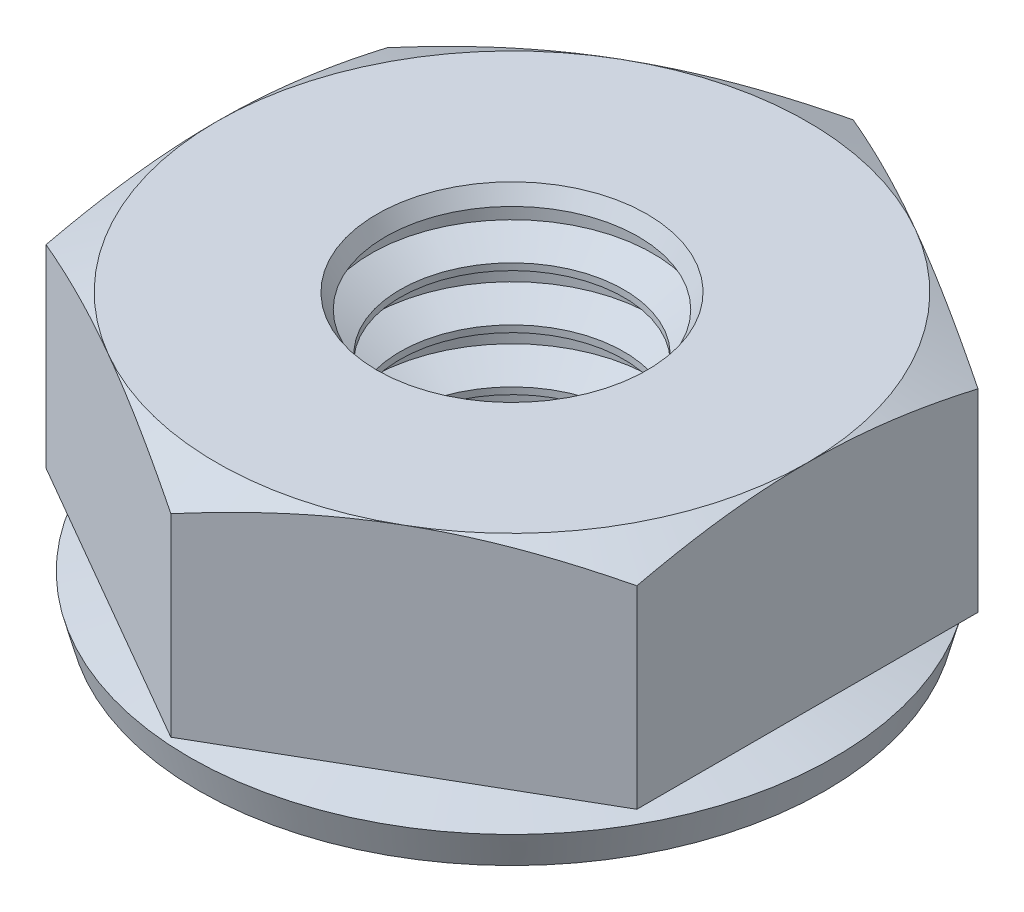
from build123d import *

# Parameters (mm, degrees)
EXTRUDE1_DEPTH  = 1.5875
LPATTERN2_COUNT = 5
LPATTERN2_PITCH = 0.79375


with BuildPart() as part:
    # Sketch1 → Extrude1 (new body, symmetric)
    with BuildSketch(Plane(origin=(0, 0, 0), x_dir=(1, 0, 0), z_dir=(0, 1, 0))):
        Polygon((0, 5.040989538), (-4.365625, 2.520494769), (-4.365625, -2.520494769), (0, -5.040989538), (4.365625, -2.520494769), (4.365625, 2.520494769), align=None)
    extrude(amount=EXTRUDE1_DEPTH, both=True)

    # Sketch2 → Cut-Revolve1 (revolve, cut)
    with BuildSketch(Plane(origin=(0, 0, 0), x_dir=(0, 0, -1), z_dir=(1, 0, 0))):
        Polygon((4.365625, 1.5875), (5.040989538, 1.5875), (5.040989538, 1.272572344), align=None)
    revolve(axis=Axis((0, 1.421434714, 0), (0, -1, 0)), mode=Mode.SUBTRACT)

    # Sketch3 → Cut-Revolve3 (revolve, cut)
    with BuildSketch(Plane.XY):
        Polygon((1.65317021, 1.48828125), (1.65317021, 1.5875), (0, 1.5875), (0, 0.79375), (1.65317021, 0.79375), (2.0828, 1.041796875), (2.0828, 1.240234375), align=None)
    cut_revolve3 = revolve(axis=Axis((0, 1.642101285, 0), (0, -1, 0)), mode=Mode.SUBTRACT)

    # LPattern2: Cut-Revolve3 ×5
    with Locations(*[(0, -i * LPATTERN2_PITCH, 0) for i in range(1, LPATTERN2_COUNT)]):
        add(cut_revolve3, mode=Mode.SUBTRACT)

    # Sketch4 → Cut-Revolve4 (revolve, cut)
    with BuildSketch(Plane.XY):
        Polygon((1.867985105, 1.364257812), (1.996874042, 1.5875), (1.65317021, 1.5875), (1.65317021, 1.48828125), align=None)
    revolve(axis=Axis((0, 1.785862642, 0), (0, -1, 0)), mode=Mode.SUBTRACT)

    # Sketch12 → Revolve1 (revolve)
    with BuildSketch(Plane(origin=(0, 0, 0), x_dir=(0, 0, -1), z_dir=(1, 0, 0))):
        Polygon((2.70049032, -1.7145), (3.749364928, -1.7145), (4.7625, -1.985968724), (4.631019925, -2.476659044), (3.617884853, -2.20519032), (2.0828, -2.20519032), (2.0828, -1.5875), (2.70049032, -1.5875), align=None)
    revolve(axis=Axis((0, 1.620050577, 0), (0, -1, 0)))


solid = part.part
